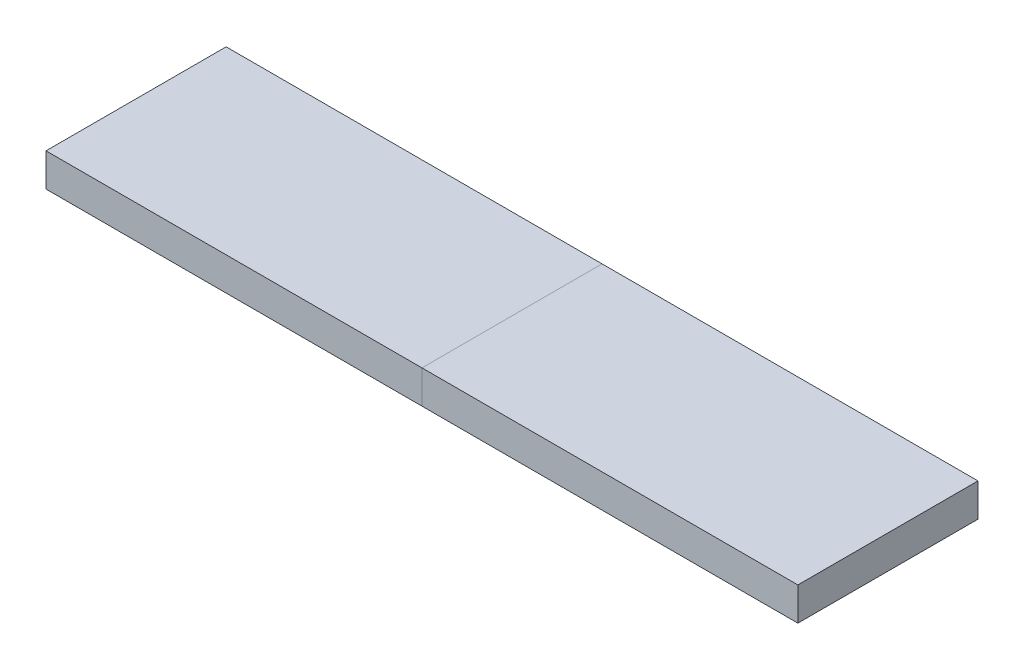
from build123d import *

# Parameters (mm, degrees)
SKETCH2_W              = 288
SKETCH2_H              = 69
BOSS_EXTRUDE1_DEPTH    = 6.35
SKETCH3_W              = 280.19375
SKETCH3_H              = 61.9125
CUT_EXTRUDE1_DEPTH     = 6.35
SKETCH4_W              = 271.35
SKETCH4_H              = 55
CUT_EXTRUDE2_DEPTH     = 4
SPLIT1_SURFACE_1_BACK  = 297.422
SPLIT1_SURFACE_1_DEPTH = 594.844
SPLIT1_SURFACE_2_BACK  = 297.422
SPLIT1_SURFACE_2_DEPTH = 594.844


with BuildPart() as part:
    # Sketch2 → Boss-Extrude1 (new, symmetric)
    with BuildSketch(Plane(origin=(0, 0, 0), x_dir=(1, 0, 0), z_dir=(0, 1, 0))):
        Rectangle(SKETCH2_W, SKETCH2_H)
    extrude(amount=BOSS_EXTRUDE1_DEPTH, both=True)

    # Sketch3 → Cut-Extrude1 (cut)
    with BuildSketch(Plane.XZ.offset(6.35)):
        Rectangle(SKETCH3_W, SKETCH3_H)
    extrude(amount=-CUT_EXTRUDE1_DEPTH, mode=Mode.SUBTRACT)

    # Sketch4 → Cut-Extrude2 (cut)
    with BuildSketch(Plane.XZ):
        Rectangle(SKETCH4_W, SKETCH4_H)
    extrude(amount=-CUT_EXTRUDE2_DEPTH, mode=Mode.SUBTRACT)


with BuildPart() as body_2:
    # Split1: the piece behind the surface
    add(part.part)
    # Split1 surface: a surface, the sketch's curves swept straight by 594.844 mm
    with BuildLine(Plane(origin=(0, 6.35, 0), x_dir=(1, 0, 0), z_dir=(0, 1, 0)).offset(-SPLIT1_SURFACE_1_BACK), mode=Mode.PRIVATE) as split1_surface_1_path:
        Line((0, -34.5), (0, 34.5))
    split1_surface_1 = Shell.extrude(split1_surface_1_path.wire(), (0 * SPLIT1_SURFACE_1_DEPTH, 1 * SPLIT1_SURFACE_1_DEPTH, 0 * SPLIT1_SURFACE_1_DEPTH))
    split(bisect_by=split1_surface_1, keep=Keep.BOTTOM)


with BuildPart() as part_1:
    add(part.part)

    # Split1: split by a surface, the side it looks to stays
    # Split1 surface: a surface, the sketch's curves swept straight by 594.844 mm
    with BuildLine(Plane(origin=(0, 6.35, 0), x_dir=(1, 0, 0), z_dir=(0, 1, 0)).offset(-SPLIT1_SURFACE_2_BACK), mode=Mode.PRIVATE) as split1_surface_2_path:
        Line((0, -34.5), (0, 34.5))
    split1_surface_2 = Shell.extrude(split1_surface_2_path.wire(), (0 * SPLIT1_SURFACE_2_DEPTH, 1 * SPLIT1_SURFACE_2_DEPTH, 0 * SPLIT1_SURFACE_2_DEPTH))
    split(bisect_by=split1_surface_2, keep=Keep.TOP)


solid = Compound([body_2.part, part_1.part])
